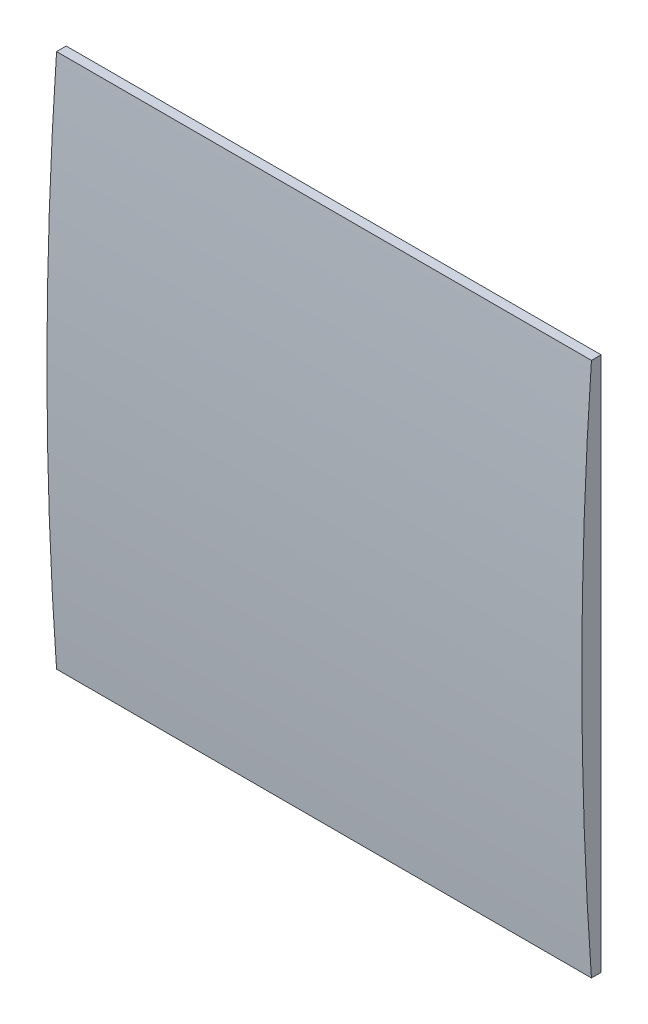
from build123d import *

# Parameters (mm, degrees)
BOSS_EXTRUDE7_DEPTH = 27.7


with BuildPart() as part:
    # Sketch14 → Boss-Extrude7 (new body)
    with BuildSketch(Plane(origin=(0, 0, 0), x_dir=(0, 0, -1), z_dir=(1, 0, 0))):
        with BuildLine():
            Line((-2.5, 27.7), (-2.5, 0))
            Line((-2.5, 0), (-3, 0))
            ThreePointArc((-3, 0), (-3.374959299, 6.920488834), (-3.5, 13.85))
            ThreePointArc((-3.5, 13.85), (-3.374959299, 20.779511166), (-3, 27.7))
            Line((-3, 27.7), (-2.5, 27.7))
        make_face()
    extrude(amount=BOSS_EXTRUDE7_DEPTH)


solid = part.part
